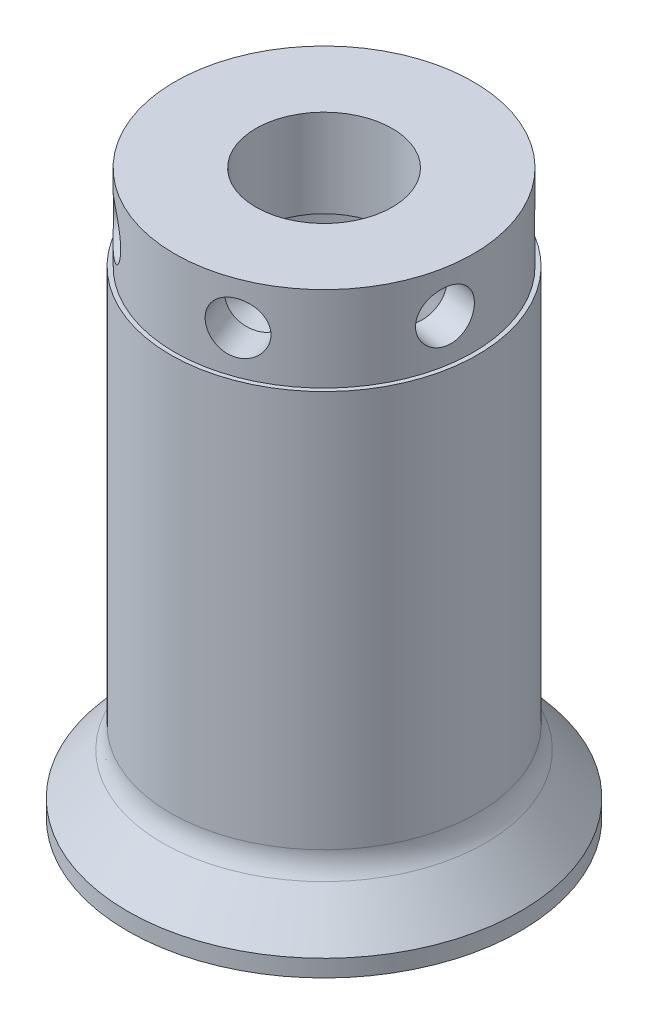
from build123d import *

# Parameters (mm, degrees)
SKETCH2_R         = 13.890625
EXTRUDE2_DEPTH    = 44.196
CIRPATTERN1_COUNT = 6
SKETCH5_R         = 6.35
EXTRUDE3_DEPTH    = 53.3875


with BuildPart() as part:
    # Sketch1 → Revolve1 (revolve)
    with BuildSketch(Plane(origin=(0, 0, 0), x_dir=(0, 0, -1), z_dir=(1, 0, 0))):
        with BuildLine():
            Line((-18.288, 0), (-18.288, 1.5875))
            Line((-18.288, 1.5875), (-15.031387054, 5.464420173))
            ThreePointArc((-15.031387054, 5.464420173), (-14.479262782, 6.419853295), (-14.2875, 7.506555048))
            Line((-14.2875, 7.506555048), (-14.2875, 44.45))
            Line((-14.2875, 44.45), (-13.890625, 44.45))
            Line((-13.890625, 44.45), (-13.890625, 52.3875))
            Line((-13.890625, 52.3875), (0, 52.3875))
            Line((0, 52.3875), (0, 0))
            Line((0, 0), (-18.288, 0))
        make_face()
    revolve(axis=Axis((0, 52.3875, 0), (0, -1, 0)))

    # Sketch2 → Extrude2 (cut)
    with BuildSketch(Plane.XZ):
        Circle(SKETCH2_R)
    extrude(amount=-EXTRUDE2_DEPTH, mode=Mode.SUBTRACT)

    # Sketch4 → 3/16 (0.1875) Diameter Hole1 (revolve, cut)
    with BuildSketch(Plane(origin=(13.702535491, 48.41875, 2.278153639), x_dir=(0.164006561, 0, -0.986459248), z_dir=(0, 1, 0))):
        Polygon((0, 0), (0, 4.732799349), (2.38125, 3.302), (2.38125, 0), align=None)
    f_3_16_0_1875_diameter_hole1 = revolve(axis=Axis((19.966551716, 48.41875, 3.319595303), (-0.986459248, 0, -0.164006561)), mode=Mode.SUBTRACT)

    # CirPattern1: 3/16 (0.1875) Diameter Hole1 ×6 about axis
    cirpattern1_axis = Axis((0, 52.3875, 0), (0, 1, 0))
    for i in range(1, CIRPATTERN1_COUNT):
        add(f_3_16_0_1875_diameter_hole1.rotate(cirpattern1_axis, i * 360 / CIRPATTERN1_COUNT), mode=Mode.SUBTRACT)

    # Sketch5 → Extrude3 (cut, through all)
    with BuildSketch(Plane(origin=(0, 52.3875, 0), x_dir=(-1, 0, 0), z_dir=(0, 1, 0))):
        Circle(SKETCH5_R)
    extrude(amount=-EXTRUDE3_DEPTH, mode=Mode.SUBTRACT)


solid = part.part
